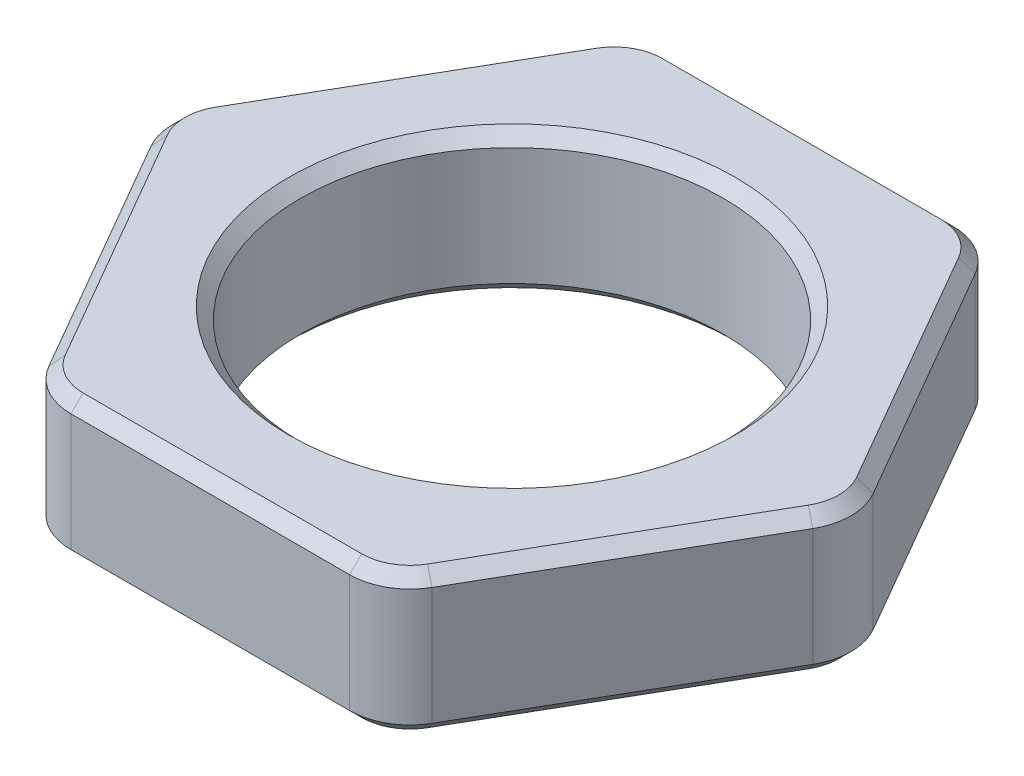
from build123d import *

# Parameters (mm, degrees)
SKETCH1_R           = 3.5
BOSS_EXTRUDE1_DEPTH = 1.175
FILLET1_R           = 1
CHAMFER1_SIZE       = 0.2


with BuildPart() as part:
    # Sketch1 → Boss-Extrude1 (new body, symmetric)
    with BuildSketch(Plane(origin=(0, 0, 0), x_dir=(1, 0, 0), z_dir=(0, 1, 0))):
        Polygon((2.886751346, 5), (-2.886751346, 5), (-5.773502692, 0), (-2.886751346, -5), (2.886751346, -5), (5.773502692, 0), align=None)
        Circle(SKETCH1_R, mode=Mode.SUBTRACT)
    extrude(amount=BOSS_EXTRUDE1_DEPTH, both=True)

    # Fillet1
    fillet1_edges = [part.edges().sort_by_distance(p)[0] for p in [
        (5.773502692, 0, 0),
        (2.886751346, 0, 5),
        (-2.886751346, 0, 5),
        (-5.773502692, 0, 0),
        (-2.886751346, 0, -5),
        (2.886751346, 0, -5),
    ]]
    fillet(fillet1_edges, radius=FILLET1_R)

    # Chamfer1
    chamfer1_edges = [part.edges().sort_by_distance(p)[0] for p in [
        (-3.5, -1.175, 0),
        (-3.5, 1.175, 0),
        (4.330127019, -1.175, -2.5),
        (4.330127019, 1.175, -2.5),
        (4.330127019, -1.175, 2.5),
        (0, -1.175, 5),
        (-4.330127019, -1.175, 2.5),
        (-4.330127019, -1.175, -2.5),
        (0, -1.175, -5),
        (-2.809401077, -1.175, 4.866025404),
        (2.809401077, -1.175, -4.866025404),
        (-2.809401077, -1.175, -4.866025404),
        (-5.618802154, -1.175, 0),
        (2.809401077, -1.175, 4.866025404),
        (5.618802154, -1.175, 0),
        (4.330127019, 1.175, 2.5),
        (0, 1.175, -5),
        (-4.330127019, 1.175, -2.5),
        (-4.330127019, 1.175, 2.5),
        (0, 1.175, 5),
        (-2.809401077, 1.175, 4.866025404),
        (2.809401077, 1.175, -4.866025404),
        (-2.809401077, 1.175, -4.866025404),
        (-5.618802154, 1.175, 0),
        (2.809401077, 1.175, 4.866025404),
        (5.618802154, 1.175, 0),
    ]]
    chamfer(chamfer1_edges, length=CHAMFER1_SIZE)


solid = part.part
